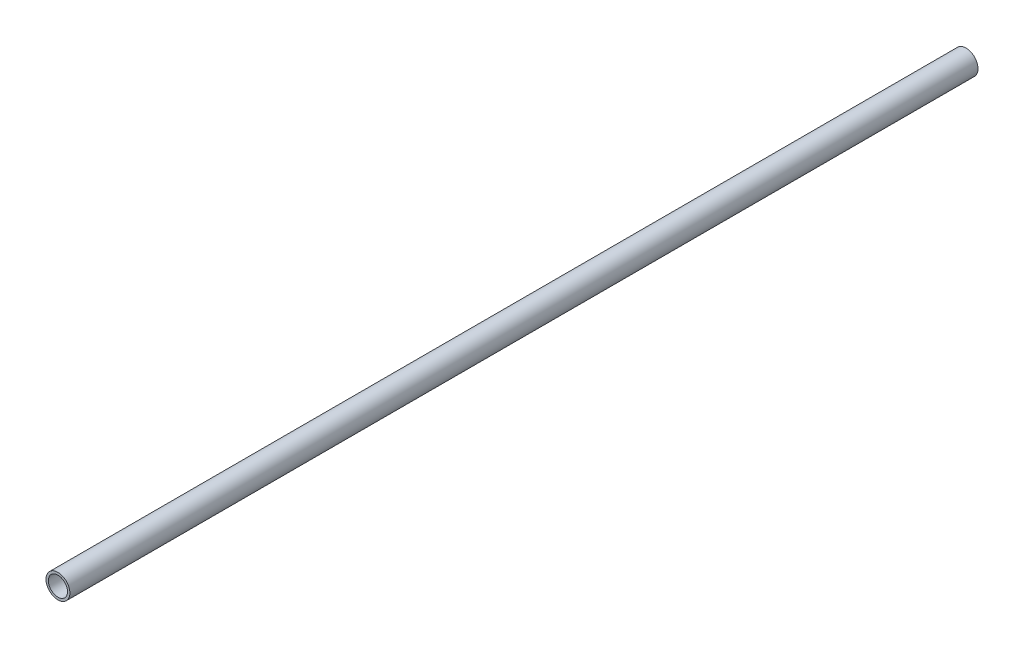
from build123d import *

# Parameters (mm, degrees)
ESBO_O1_R                = 5
ESBO_O1_R_2              = 4
RESSALTO_EXTRUS_O1_DEPTH = 380


with BuildPart() as part:
    # Esboço1 → Ressalto-extrusão1 (new body)
    with BuildSketch(Plane.XY):
        Circle(ESBO_O1_R)
        Circle(ESBO_O1_R_2, mode=Mode.SUBTRACT)
    extrude(amount=RESSALTO_EXTRUS_O1_DEPTH)


solid = part.part
